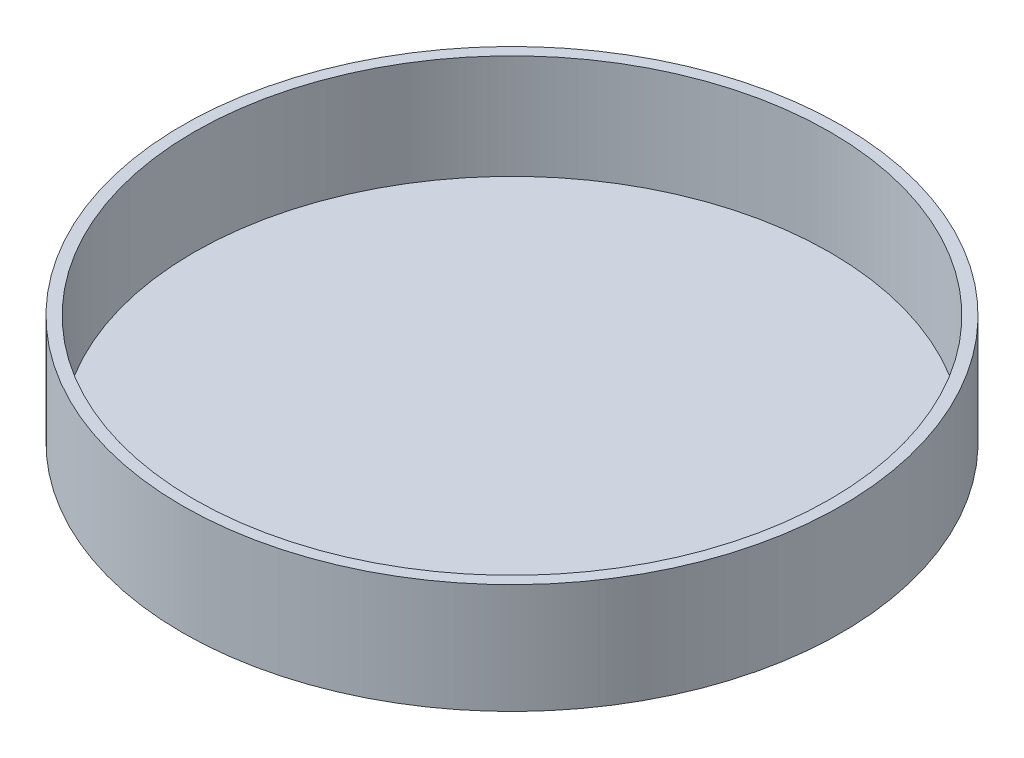
from build123d import *

# Parameters (mm, degrees)
SKETCH1_R           = 152.4
SKETCH1_R_2         = 147.105988381
BOSS_EXTRUDE1_DEPTH = 50.8
SKETCH3_R           = 147.105988381
BOSS_EXTRUDE2_DEPTH = 2.54


with BuildPart() as part:
    # Sketch1 → Boss-Extrude1 (new body)
    with BuildSketch(Plane(origin=(0, 0, 0), x_dir=(1, 0, 0), z_dir=(0, 1, 0))):
        Circle(SKETCH1_R)
        Circle(SKETCH1_R_2, mode=Mode.SUBTRACT)
    extrude(amount=BOSS_EXTRUDE1_DEPTH)


with BuildPart() as body_2:
    # Sketch3 → Boss-Extrude2 (new body)
    with BuildSketch(Plane.XZ):
        Circle(SKETCH3_R)
    extrude(amount=-BOSS_EXTRUDE2_DEPTH)


solid = Compound([part.part, body_2.part])
